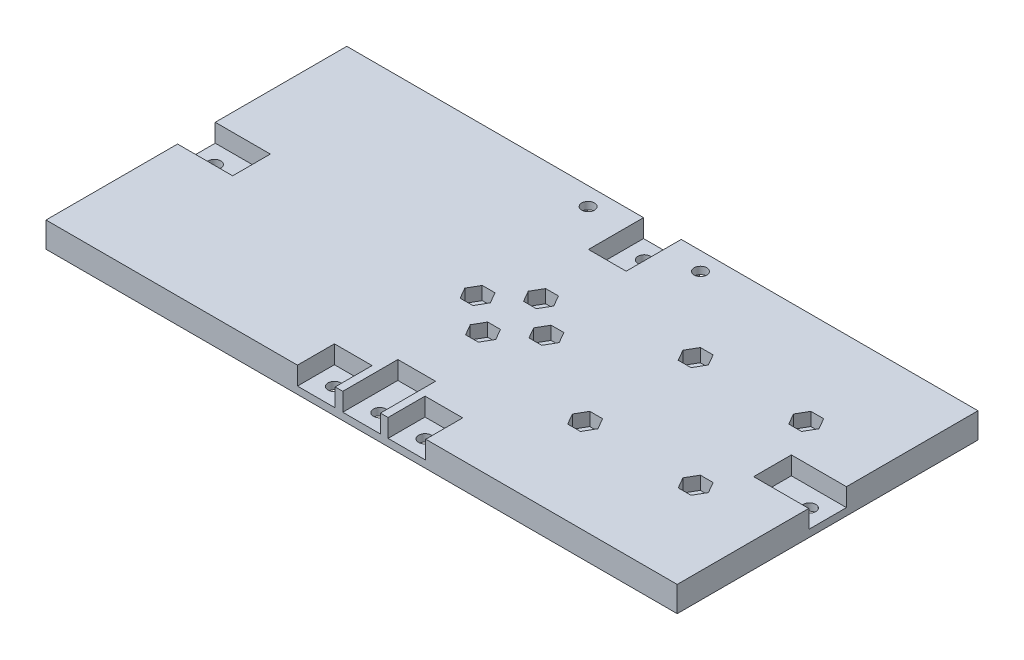
from build123d import *

# Parameters (mm, degrees)
SKETCH1_W           = 174.17
SKETCH1_H           = 83
BOSS_EXTRUDE1_DEPTH = 7
SKETCH2_R           = 1.75
CUT_EXTRUDE1_DEPTH  = 8
SKETCH3_R           = 1.75
CUT_EXTRUDE2_DEPTH  = 8
SKETCH4_W           = 15.4
SKETCH4_H           = 10.4
SKETCH4_W_2         = 10.4
SKETCH4_H_2         = 15.4
CUT_EXTRUDE3_DEPTH  = 5
SKETCH5_W           = 10.4
SKETCH5_H           = 10.4
CUT_EXTRUDE4_DEPTH  = 5
SKETCH6_R           = 1.75
CUT_EXTRUDE5_DEPTH  = 3
SKETCH12_R          = 1.75
CUT_EXTRUDE9_DEPTH  = 8
CUT_EXTRUDE6_DEPTH  = 3.64
SKETCH9_W           = 10.4
SKETCH9_H           = 10.4
CUT_EXTRUDE7_DEPTH  = 5
SKETCH10_R          = 1.75
CUT_EXTRUDE8_DEPTH  = 3


with BuildPart() as part:
    # Sketch1 → Boss-Extrude1 (new body)
    with BuildSketch(Plane(origin=(0, 0, 0), x_dir=(1, 0, 0), z_dir=(0, 1, 0))):
        with Locations((87.085, 41.5)):
            Rectangle(SKETCH1_W, SKETCH1_H)
    extrude(amount=BOSS_EXTRUDE1_DEPTH)

    # Sketch2 → Cut-Extrude1 (cut, through all)
    with BuildSketch(Plane(origin=(0, 7, 0), x_dir=(1, 0, 0), z_dir=(0, 1, 0))):
        with Locations((87.085, 49.5)):
            Circle(SKETCH2_R)
        with Locations((77.585, 41.5)):
            Circle(SKETCH2_R)
        with Locations((96.585, 41.5)):
            Circle(SKETCH2_R)
        with Locations((87.085, 33.5)):
            Circle(SKETCH2_R)
    extrude(amount=-CUT_EXTRUDE1_DEPTH, mode=Mode.SUBTRACT)

    # Sketch3 → Cut-Extrude2 (cut, through all)
    with BuildSketch(Plane(origin=(0, 7, 0), x_dir=(1, 0, 0), z_dir=(0, 1, 0))):
        with Locations((87.085, 78)):
            Circle(SKETCH3_R)
        with Locations((5, 41.5)):
            Circle(SKETCH3_R)
        with Locations((87.085, 5)):
            Circle(SKETCH3_R)
        with Locations((169.17, 41.5)):
            Circle(SKETCH3_R)
    extrude(amount=-CUT_EXTRUDE2_DEPTH, mode=Mode.SUBTRACT)

    # Sketch4 → Cut-Extrude3 (cut)
    with BuildSketch(Plane(origin=(0, 7, 0), x_dir=(1, 0, 0), z_dir=(0, 1, 0))):
        with Locations((7.5, 41.5)):
            Rectangle(SKETCH4_W, SKETCH4_H)
        with Locations((87.085, 7.5)):
            Rectangle(SKETCH4_W_2, SKETCH4_H_2)
        with Locations((87.085, 75.5)):
            Rectangle(SKETCH4_W_2, SKETCH4_H_2)
        with Locations((166.67, 41.5)):
            Rectangle(SKETCH4_W, SKETCH4_H)
    extrude(amount=-CUT_EXTRUDE3_DEPTH, mode=Mode.SUBTRACT)

    # Sketch5 → Cut-Extrude4 (cut)
    with BuildSketch(Plane(origin=(0, 7, 0), x_dir=(1, 0, 0), z_dir=(0, 1, 0))):
        with Locations((74.585, 5)):
            Rectangle(SKETCH5_W, SKETCH5_H)
        with Locations((99.585, 5)):
            Rectangle(SKETCH5_W, SKETCH5_H)
    extrude(amount=-CUT_EXTRUDE4_DEPTH, mode=Mode.SUBTRACT)

    # Sketch6 → Cut-Extrude5 (cut, through all)
    with BuildSketch(Plane(origin=(0, 2, 0), x_dir=(1, 0, 0), z_dir=(0, 1, 0))):
        with Locations((74.585, 5)):
            Circle(SKETCH6_R)
        with Locations((99.585, 5)):
            Circle(SKETCH6_R)
    extrude(amount=-CUT_EXTRUDE5_DEPTH, mode=Mode.SUBTRACT)

    # Sketch12 → Cut-Extrude9 (cut, through all)
    with BuildSketch(Plane.XZ):
        with Locations((122.51393219, -26.25)):
            Circle(SKETCH12_R)
        with Locations((153.01393219, -26.25)):
            Circle(SKETCH12_R)
        with Locations((122.51393219, -56.75)):
            Circle(SKETCH12_R)
        with Locations((153.01393219, -56.75)):
            Circle(SKETCH12_R)
    extrude(amount=-CUT_EXTRUDE9_DEPTH, mode=Mode.SUBTRACT)

    # Sketch7 → Cut-Extrude6 (cut)
    with BuildSketch(Plane(origin=(0, 7, 0), x_dir=(1, 0, 0), z_dir=(0, 1, 0))):
        Polygon((75.824081679, 44.55), (79.345918321, 44.55), (81.106836642, 41.5), (79.345918321, 38.45), (75.824081679, 38.45), (74.063163358, 41.5), align=None)
        Polygon((85.324081679, 52.55), (88.845918321, 52.55), (90.606836642, 49.5), (88.845918321, 46.45), (85.324081679, 46.45), (83.563163358, 49.5), align=None)
        Polygon((100.106836642, 41.5), (98.345918321, 44.55), (94.824081679, 44.55), (93.063163358, 41.5), (94.824081679, 38.45), (98.345918321, 38.45), align=None)
        Polygon((83.563163358, 33.5), (85.324081679, 30.45), (88.845918321, 30.45), (90.606836642, 33.5), (88.845918321, 36.55), (85.324081679, 36.55), align=None)
        Polygon((120.753013869, 29.3), (124.274850511, 29.3), (126.035768832, 26.25), (124.274850511, 23.2), (120.753013869, 23.2), (118.992095548, 26.25), align=None)
        Polygon((151.253013869, 29.3), (154.774850511, 29.3), (156.535768832, 26.25), (154.774850511, 23.2), (151.253013869, 23.2), (149.492095548, 26.25), align=None)
        Polygon((151.253013869, 59.8), (154.774850511, 59.8), (156.535768832, 56.75), (154.774850511, 53.7), (151.253013869, 53.7), (149.492095548, 56.75), align=None)
        Polygon((120.753013869, 59.8), (124.274850511, 59.8), (126.035768832, 56.75), (124.274850511, 53.7), (120.753013869, 53.7), (118.992095548, 56.75), align=None)
    extrude(amount=-CUT_EXTRUDE6_DEPTH, mode=Mode.SUBTRACT)

    # Sketch9 → Cut-Extrude7 (cut)
    with BuildSketch(Plane.XZ):
        with Locations((71.585, -78)):
            Rectangle(SKETCH9_W, SKETCH9_H)
        with Locations((102.585, -78)):
            Rectangle(SKETCH9_W, SKETCH9_H)
    extrude(amount=-CUT_EXTRUDE7_DEPTH, mode=Mode.SUBTRACT)

    # Sketch10 → Cut-Extrude8 (cut, through all)
    with BuildSketch(Plane.XZ.offset(-5)):
        with Locations((71.585, -78)):
            Circle(SKETCH10_R)
        with Locations((102.585, -78)):
            Circle(SKETCH10_R)
    extrude(amount=-CUT_EXTRUDE8_DEPTH, mode=Mode.SUBTRACT)


solid = part.part
